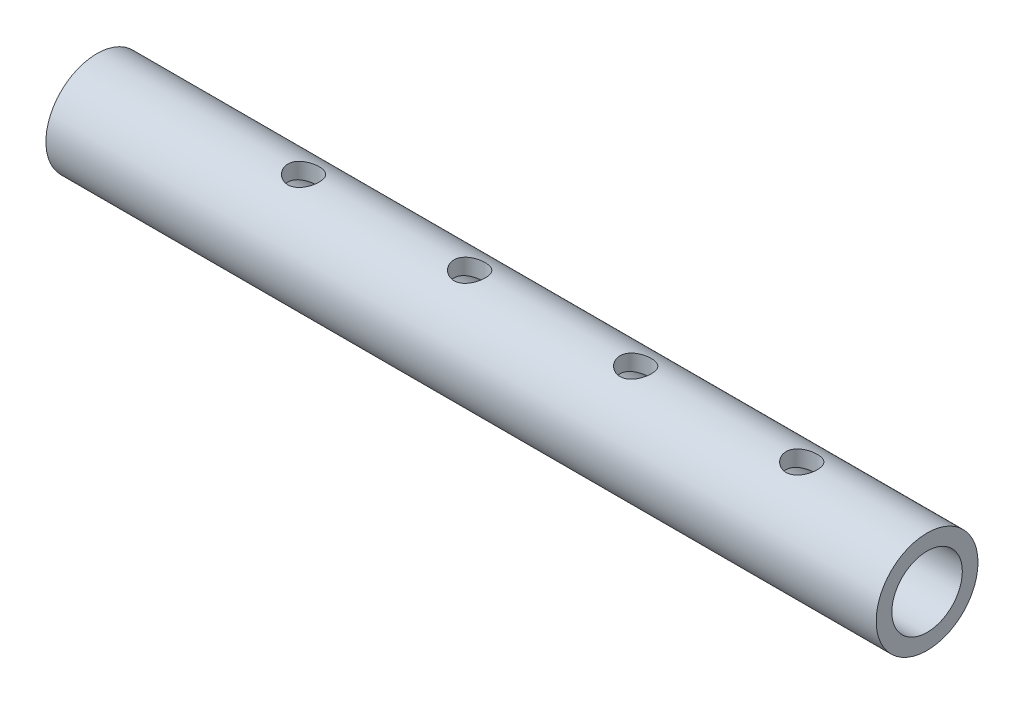
from build123d import *

# Parameters (mm, degrees)
SWEEP_THIN1_PROFILE_R   = 16.25
SWEEP_THIN1_PROFILE_R_2 = 11.25
SKETCH3_R               = 5
CUT_EXTRUDE1_DEPTH      = 381.262213736
CUT_EXTRUDE1_DEPTH_BACK = 381.262213736


with BuildPart() as part:
    # Sweep-Thin1: sweep along a path in Sketch2
    with BuildLine(Plane(origin=(0, 0, 0), x_dir=(1, 0, 0), z_dir=(0, 1, 0))) as sweep_thin1_path:
        Line((60.301746377, 180), (325.301746377, 180))
    # Sweep-Thin1 profile (on start of the path) → Sweep-Thin1 (sweep)
    with BuildSketch(Plane(origin=(60.301746377, 0, -180), x_dir=(0, 0, 1), z_dir=(1, 0, 0))):
        Circle(SWEEP_THIN1_PROFILE_R)
        Circle(SWEEP_THIN1_PROFILE_R_2, mode=Mode.SUBTRACT)
    sweep(path=sweep_thin1_path.line)

    # Sketch3 → Cut-Extrude1 (cut, two sides)
    with BuildSketch(Plane(origin=(0, 0, 0), x_dir=(1, 0, 0), z_dir=(0, 1, 0))) as cut_extrude1_sk:
        with Locations(Location((126.301746377, 180, 0), (0, 0, 270))):
            Circle(SKETCH3_R)
        with Locations(Location((179.301746377, 180, 0), (0, 0, 270))):
            Circle(SKETCH3_R)
        with Locations(Location((232.301746377, 180, 0), (0, 0, 270))):
            Circle(SKETCH3_R)
        with Locations(Location((285.301746377, 180, 0), (0, 0, 270))):
            Circle(SKETCH3_R)
    extrude(amount=CUT_EXTRUDE1_DEPTH, mode=Mode.SUBTRACT)
    extrude(cut_extrude1_sk.sketch, amount=-CUT_EXTRUDE1_DEPTH_BACK, mode=Mode.SUBTRACT)


solid = part.part
